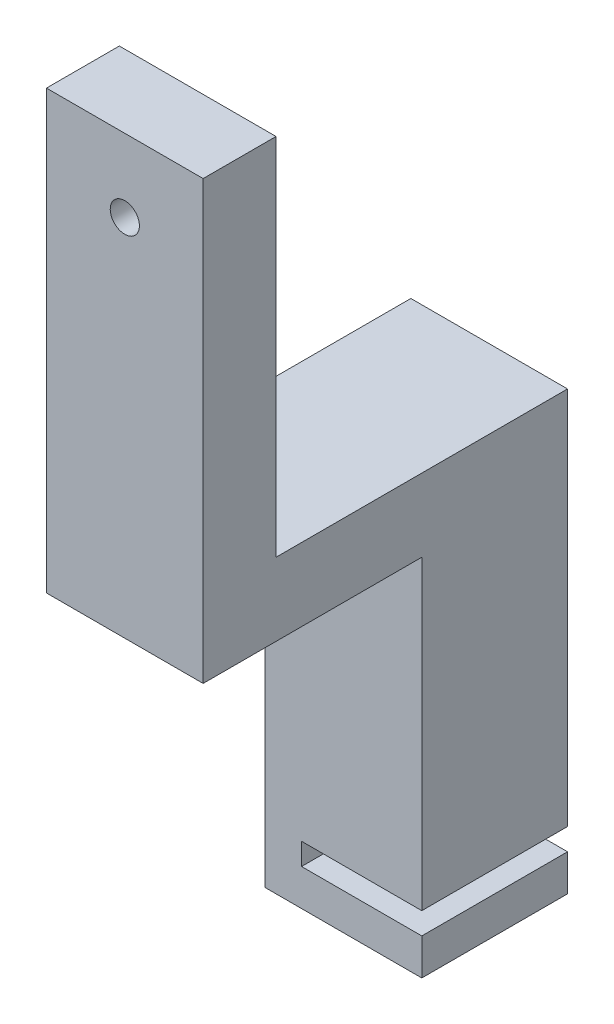
from build123d import *

# Parameters (mm, degrees)
BOSS_EXTRUDE1_DEPTH = 20
SKETCH1_2_W         = 21.5
SKETCH1_2_H         = 60
BOSS_EXTRUDE2_DEPTH = 50
SKETCH3_W           = 40
SKETCH3_H           = 50
CUT_EXTRUDE1_DEPTH  = 50
SKETCH4_R           = 2
CUT_EXTRUDE2_DEPTH  = 50


with BuildPart() as part:
    # Sketch1 → Boss-Extrude1 (new body)
    with BuildSketch(Plane.XY):
        Polygon((0, 8), (0, 50), (0, 110), (-21.5, 110), (-21.5, 50), (-21.5, 0), (0, 0), (0, 5), (-16.5, 5), (-16.5, 8), align=None)
    extrude(amount=BOSS_EXTRUDE1_DEPTH)

    # Sketch1_2 → Boss-Extrude2 (add)
    with BuildSketch(Plane.XY):
        with Locations((-10.75, 80)):
            Rectangle(SKETCH1_2_W, SKETCH1_2_H)
    extrude(amount=BOSS_EXTRUDE2_DEPTH)

    # Sketch3 → Cut-Extrude1 (cut)
    with BuildSketch(Plane(origin=(0, 0, 0), x_dir=(0, 0, -1), z_dir=(1, 0, 0))):
        with Locations((-20, 85)):
            Rectangle(SKETCH3_W, SKETCH3_H)
    extrude(amount=-CUT_EXTRUDE1_DEPTH, mode=Mode.SUBTRACT)

    # Sketch4 → Cut-Extrude2 (cut)
    with BuildSketch(Plane(origin=(0, 0, 40), x_dir=(-1, 0, 0), z_dir=(0, 0, -1))):
        with Locations((10.75, 100)):
            Circle(SKETCH4_R)
    extrude(amount=-CUT_EXTRUDE2_DEPTH, mode=Mode.SUBTRACT)


solid = part.part
